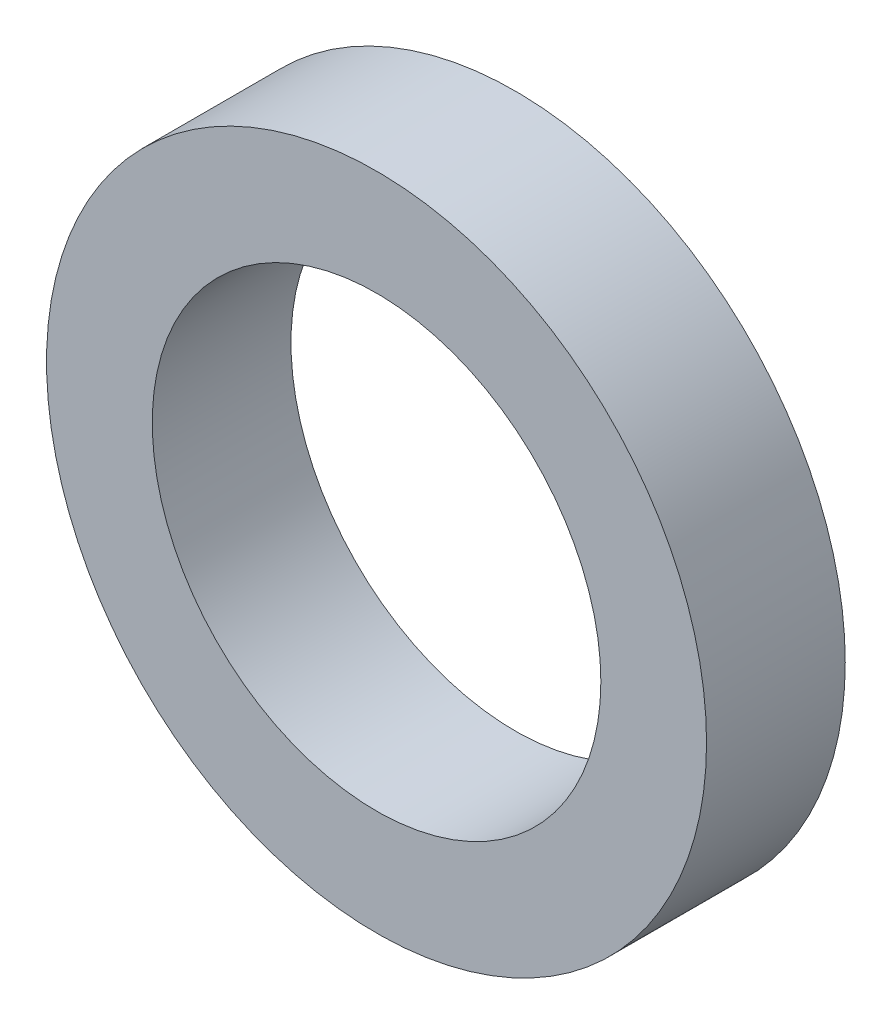
from build123d import *

# Parameters (mm, degrees)
SKETCH1_R           = 128
SKETCH1_R_2         = 87
BOSS_EXTRUDE2_DEPTH = 53.8


with BuildPart() as part:
    # Sketch1 → Boss-Extrude2 (new body)
    with BuildSketch(Plane.XY):
        Circle(SKETCH1_R)
        Circle(SKETCH1_R_2, mode=Mode.SUBTRACT)
    extrude(amount=BOSS_EXTRUDE2_DEPTH)


solid = part.part
